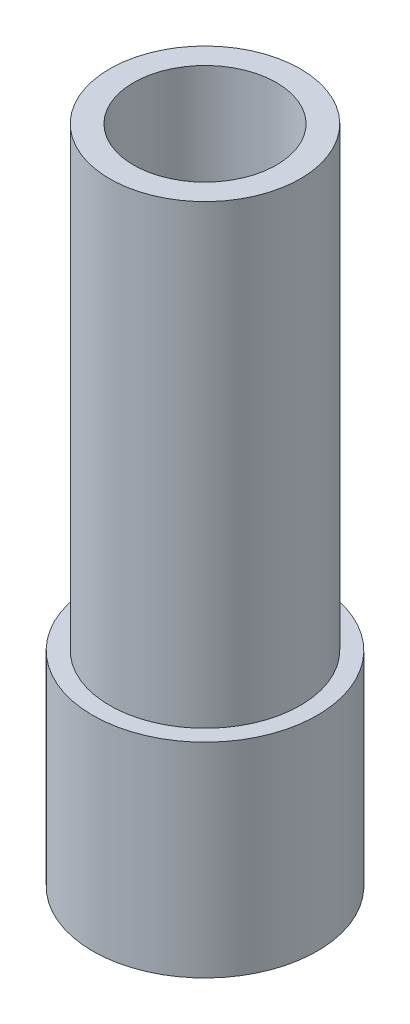
from build123d import *


with BuildPart() as part:
    # Sketch2 → Revolve1 (revolve)
    with BuildSketch(Plane.XY):
        Polygon((10.5, 0), (4.5, 0), (4.5, -6), (13.5, -6), (13.5, -11), (16.5, -11), (16.5, -6), (16.5, 19), (14, 19), (14, 86), (10.5, 86), align=None)
    revolve(axis=Axis((0, 0, 0), (0, 1, 0)))


solid = part.part
